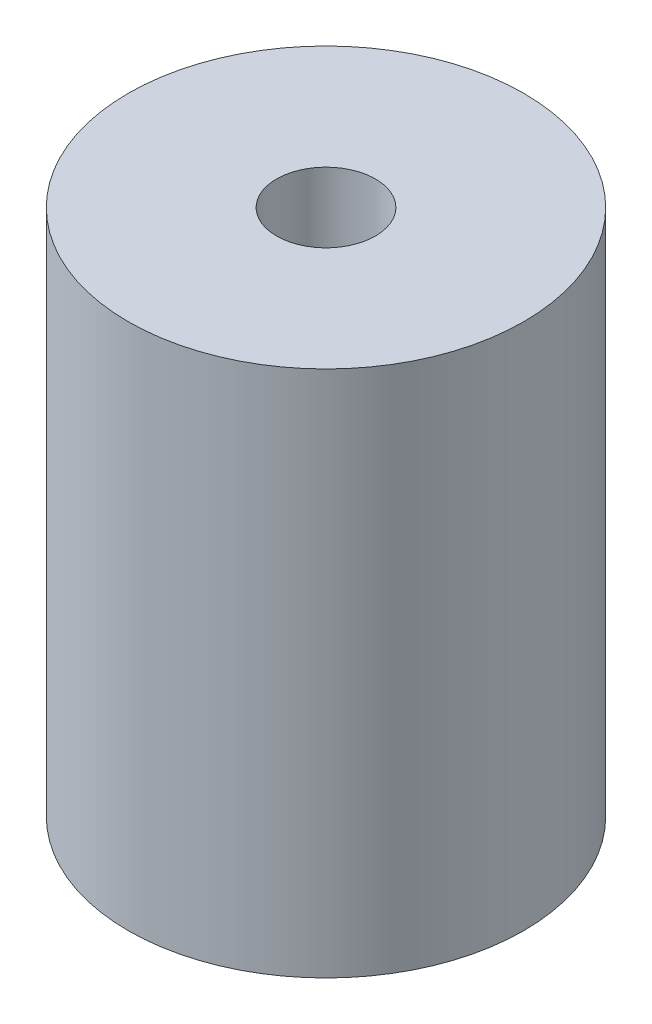
from build123d import *

# Parameters (mm, degrees)
SKETCH1_R           = 12
SKETCH1_R_2         = 3
BOSS_EXTRUDE1_DEPTH = 16


with BuildPart() as part:
    # Sketch1 → Boss-Extrude1 (new body, symmetric)
    with BuildSketch(Plane(origin=(0, 0, 0), x_dir=(1, 0, 0), z_dir=(0, 1, 0))):
        Circle(SKETCH1_R)
        Circle(SKETCH1_R_2, mode=Mode.SUBTRACT)
    extrude(amount=BOSS_EXTRUDE1_DEPTH, both=True)


solid = part.part
